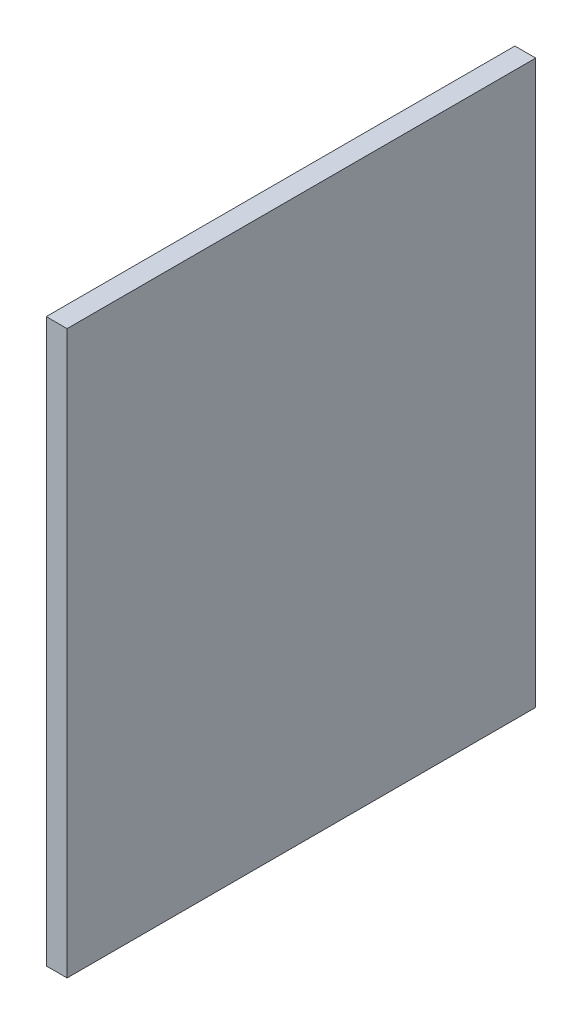
from build123d import *

# Parameters (mm, degrees)
CROQUIS2_W              = 135
CROQUIS2_H              = 162
SALIENTE_EXTRUIR1_DEPTH = 6


with BuildPart() as part:
    # Croquis2 → Saliente-Extruir1 (new body)
    with BuildSketch(Plane(origin=(0, 0, 0), x_dir=(0, 0, -1), z_dir=(1, 0, 0))):
        Rectangle(CROQUIS2_W, CROQUIS2_H)
    extrude(amount=SALIENTE_EXTRUIR1_DEPTH)


solid = part.part
